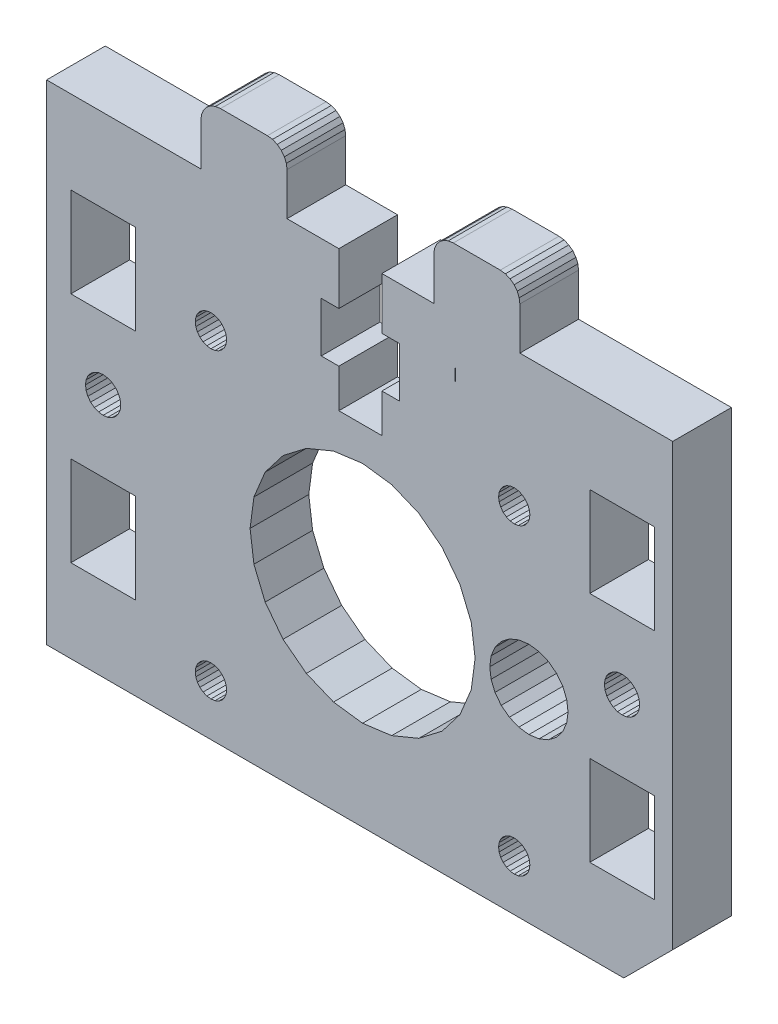
from build123d import *

# Parameters (mm, degrees)
SKETCH1_W           = 6.599987016
SKETCH1_H           = 9.199995837
SKETCH1_H_2         = 9.1999977
SKETCH1_W_2         = 6.600001917
BOSS_EXTRUDE1_DEPTH = 6


with BuildPart() as part:
    # Sketch1 → Boss-Extrude1 (new body)
    with BuildSketch(Plane.XY):
        Polygon((297.467575584, 143.892964543), (297.467575584, 138.592965721), (295.667577352, 138.592965721), (295.667577352, 133.492967957), (297.467575584, 133.492967957), (297.467575584, 129.542968134), (301.867580255, 129.542968134), (301.867580255, 133.492967957), (303.667578487, 133.492967957), (303.667578487, 138.592965721), (301.867580255, 138.592965721), (301.867580255, 143.892964543), (307.16757751, 143.892964543), (307.16757751, 148.242962434), (307.235725858, 148.760600524), (307.435526703, 149.242962434), (307.753363948, 149.657175996), (308.16757751, 149.975013242), (308.64993942, 150.174814087), (309.16757751, 150.242962434), (313.967571952, 150.242962434), (314.485210043, 150.174814087), (314.967571952, 149.975013242), (315.381785515, 149.657175996), (315.69962276, 149.242962434), (315.899423605, 148.760600524), (315.967571952, 148.242962434), (315.967571952, 143.892964543), (331.592559343, 143.892964543), (331.592559343, 98.89297867), (326.592560943, 93.89298027), (267.592586265, 93.89298027), (267.59259138, 143.892964543), (283.367587612, 143.892964543), (283.367587612, 148.242962434), (283.435735959, 148.760600524), (283.635536804, 149.242962434), (283.953374049, 149.657175996), (284.367587612, 149.975013242), (284.849949522, 150.174814087), (285.367587612, 150.242962434), (290.167583577, 150.242962434), (290.685221667, 150.174814087), (291.167583577, 149.975013242), (291.581797139, 149.657175996), (291.899634384, 149.242962434), (292.099435229, 148.760600524), (292.167583577, 148.242962434), (292.167583577, 143.892964543), align=None)
        Polygon((314.89257136, 118.057074349), (314.0641445, 117.421400062), (313.428470213, 116.592973202), (313.028868651, 115.628249691), (312.892572, 114.592973842), (313.028868651, 113.557697993), (313.428470213, 112.592974482), (314.0641445, 111.764547622), (314.89257136, 111.128873335), (315.857294871, 110.729271773), (316.89257072, 110.592975122), (317.927846569, 110.729271773), (318.89257008, 111.128873335), (319.72099694, 111.764547622), (320.356671227, 112.592974482), (320.756272789, 113.557697993), (320.89256944, 114.592973842), (320.756272789, 115.628249691), (320.356671227, 116.592973202), (319.72099694, 117.421400062), (318.89257008, 118.057074349), (317.927846569, 118.456675911), (316.89257072, 118.592972562), (315.857294871, 118.456675911), align=None, mode=Mode.SUBTRACT)
        Polygon((284.39258112, 100.69297829), (283.97847078, 100.63845963), (283.592581376, 100.478619005), (283.261210632, 100.22434929), (283.006940917, 99.892978546), (282.847100292, 99.507089142), (282.792581632, 99.092978802), (282.847100292, 98.678868462), (283.006940917, 98.292979058), (283.261210632, 97.961608314), (283.592581376, 97.707338599), (283.97847078, 97.547497975), (284.39258112, 97.492979314), (284.80669146, 97.547497975), (285.192580864, 97.707338599), (285.523951608, 97.961608314), (285.778221323, 98.292979058), (285.938061947, 98.678868462), (285.992580608, 99.092978802), (285.938061947, 99.507089142), (285.778221323, 99.892978546), (285.523951608, 100.22434929), (285.192580864, 100.478619005), (284.80669146, 100.63845963), align=None, mode=Mode.SUBTRACT)
        Polygon((311.000719608, 111.616555776), (311.39257248, 114.592973842), (311.000719608, 117.569391908), (309.851865116, 120.342972002), (308.024301541, 122.724699224), (305.64257432, 124.552262799), (302.868994226, 125.70111729), (299.89257616, 126.092970162), (296.916158094, 125.70111729), (294.142578, 124.552262799), (291.760850778, 122.724699224), (289.933287203, 120.342972002), (288.784432712, 117.569391908), (288.39257984, 114.592973842), (288.784432712, 111.616555776), (289.933287203, 108.842975682), (291.760850778, 106.461248461), (294.142578, 104.633684885), (296.916158094, 103.484830394), (299.89257616, 103.092977522), (302.868994226, 103.484830394), (305.64257432, 104.633684885), (308.024301541, 106.461248461), (309.851865116, 108.842975682), align=None, mode=Mode.SUBTRACT)
        Polygon((315.80668154, 131.63844971), (315.3925712, 131.69296837), (314.97846086, 131.63844971), (314.592571456, 131.478609085), (314.261200712, 131.22433937), (314.006930997, 130.892968626), (313.847090372, 130.507079222), (313.792571712, 130.092968882), (313.847090372, 129.678858542), (314.006930997, 129.292969138), (314.261200712, 128.961598394), (314.592571456, 128.707328679), (314.97846086, 128.547488055), (315.3925712, 128.492969394), (315.80668154, 128.547488055), (316.192570944, 128.707328679), (316.523941688, 128.961598394), (316.778211403, 129.292969138), (316.938052027, 129.678858542), (316.992570688, 130.092968882), (316.938052027, 130.507079222), (316.778211403, 130.892968626), (316.523941688, 131.22433937), (316.192570944, 131.478609085), align=None, mode=Mode.SUBTRACT)
        Polygon((274.932923974, 119.793835074), (274.646596284, 120.166984584), (274.273446774, 120.453312273), (273.838904966, 120.633305384), (273.372584166, 120.694697682), (272.906263367, 120.633305384), (272.471721559, 120.453312273), (272.098572049, 120.166984584), (271.812244359, 119.793835074), (271.632251249, 119.359293266), (271.570858951, 118.892972466), (271.632251249, 118.426651666), (271.812244359, 117.992109858), (272.098572049, 117.618960348), (272.471721559, 117.332632659), (272.906263367, 117.152639548), (273.372584166, 117.09124725), (273.838904966, 117.152639548), (274.273446774, 117.332632659), (274.646596284, 117.618960348), (274.932923974, 117.992109858), (275.112917084, 118.426651666), (275.174309382, 118.892972466), (275.112917084, 119.359293266), align=None, mode=Mode.SUBTRACT)
        Polygon((324.852228346, 119.793835074), (324.672235236, 119.359293266), (324.610842938, 118.892972466), (324.672235236, 118.426651666), (324.852228346, 117.992109858), (325.138556036, 117.618960348), (325.511705546, 117.332632659), (325.946247354, 117.152639548), (326.412568154, 117.09124725), (326.878888953, 117.152639548), (327.313430761, 117.332632659), (327.686580271, 117.618960348), (327.972907961, 117.992109858), (328.152901071, 118.426651666), (328.214293369, 118.892972466), (328.152901071, 119.359293266), (327.972907961, 119.793835074), (327.686580271, 120.166984584), (327.313430761, 120.453312273), (326.878888953, 120.633305384), (326.412568154, 120.694697682), (325.946247354, 120.633305384), (325.511705546, 120.453312273), (325.138556036, 120.166984584), align=None, mode=Mode.SUBTRACT)
        Polygon((285.778221323, 130.892968626), (285.523951608, 131.22433937), (285.192580864, 131.478609085), (284.80669146, 131.63844971), (284.39258112, 131.69296837), (283.97847078, 131.63844971), (283.592581376, 131.478609085), (283.261210632, 131.22433937), (283.006940917, 130.892968626), (282.847100292, 130.507079222), (282.792581632, 130.092968882), (282.847100292, 129.678858542), (283.006940917, 129.292969138), (283.261210632, 128.961598394), (283.592581376, 128.707328679), (283.97847078, 128.547488055), (284.39258112, 128.492969394), (284.80669146, 128.547488055), (285.192580864, 128.707328679), (285.523951608, 128.961598394), (285.778221323, 129.292969138), (285.938061947, 129.678858542), (285.992580608, 130.092968882), (285.938061947, 130.507079222), align=None, mode=Mode.SUBTRACT)
        with Locations((273.372586045, 130.792968516)):
            Rectangle(SKETCH1_W, SKETCH1_H, mode=Mode.SUBTRACT)
        Polygon((315.80668154, 97.547497975), (316.192570944, 97.707338599), (316.523941688, 97.961608314), (316.778211403, 98.292979058), (316.938052027, 98.678868462), (316.992570688, 99.092978802), (316.938052027, 99.507089142), (316.778211403, 99.892978546), (316.523941688, 100.22434929), (316.192570944, 100.478619005), (315.80668154, 100.63845963), (315.3925712, 100.69297829), (314.97846086, 100.63845963), (314.592571456, 100.478619005), (314.261200712, 100.22434929), (314.006930997, 99.892978546), (313.847090372, 99.507089142), (313.792571712, 99.092978802), (313.847090372, 98.678868462), (314.006930997, 98.292979058), (314.261200712, 97.961608314), (314.592571456, 97.707338599), (314.97846086, 97.547497975), (315.3925712, 97.492979314), align=None, mode=Mode.SUBTRACT)
        with Locations((273.372586045, 106.992977687)):
            Rectangle(SKETCH1_W, SKETCH1_H_2, mode=Mode.SUBTRACT)
        with Locations((326.412567193, 130.792968516)):
            Rectangle(SKETCH1_W_2, SKETCH1_H, mode=Mode.SUBTRACT)
        with Locations((326.412567193, 106.992977687)):
            Rectangle(SKETCH1_W_2, SKETCH1_H_2, mode=Mode.SUBTRACT)
        Polygon((309.358126506, 139.240351042), (309.378223447, 139.336539471), (309.358126506, 137.567142201), align=None, mode=Mode.SUBTRACT)
    extrude(amount=BOSS_EXTRUDE1_DEPTH)


solid = part.part
